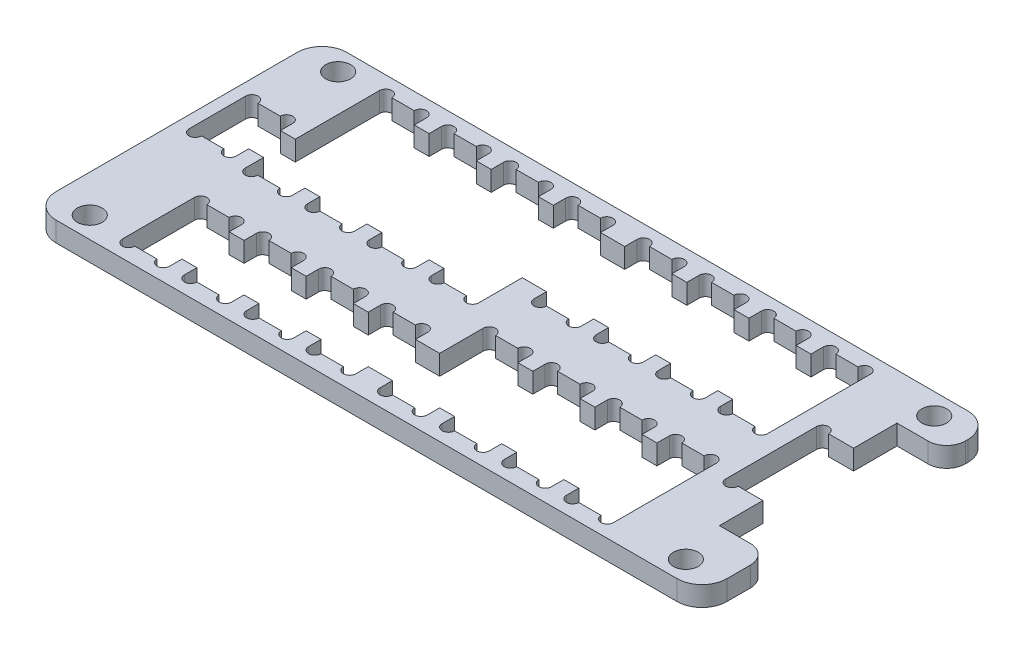
from build123d import *

# Parameters (mm, degrees)
ESQUISSE1_R             = 1
BASE_DEPTH              = 1.6
TROUS_MOLEX_DEPTH       = 2.6
ESQUISSE3_W             = 1.2
ESQUISSE3_H             = 2.55
ESQUISSE3_H_2           = 3.8
ESQUISSE3_H_3           = 8.8
ESQUISSE3_H_4           = 6.3
ESQUISSE3_W_2           = 1.95
ENL_V_MAT_EXTRU_4_DEPTH = 2.6


with BuildPart() as part:
    # Esquisse1 → base (new body)
    with BuildSketch(Plane(origin=(0, 0, 0), x_dir=(1, 0, 0), z_dir=(0, 1, 0))):
        with BuildLine():
            Line((-149, -101.7), (-99, -101.7))
            ThreePointArc((-99, -101.7), (-97.585786438, -101.114213562), (-97, -99.7))
            Line((-97, -99.7), (-97, -80.3))
            ThreePointArc((-97, -80.3), (-97.585786438, -78.885786438), (-99, -78.3))
            Line((-99, -78.3), (-149, -78.3))
            ThreePointArc((-149, -78.3), (-150.414213562, -78.885786438), (-151, -80.3))
            Line((-151, -80.3), (-151, -99.7))
            ThreePointArc((-151, -99.7), (-150.414213562, -101.114213562), (-149, -101.7))
        make_face()
        with Locations((-100, -80)):
            Circle(ESQUISSE1_R, mode=Mode.SUBTRACT)
        with Locations((-100, -100)):
            Circle(ESQUISSE1_R, mode=Mode.SUBTRACT)
        with Locations((-148, -100)):
            Circle(ESQUISSE1_R, mode=Mode.SUBTRACT)
        with Locations((-148, -80)):
            Circle(ESQUISSE1_R, mode=Mode.SUBTRACT)
    extrude(amount=BASE_DEPTH)

    # Esquisse2 → trous molex (cut, through all)
    with BuildSketch(Plane(origin=(0, 0, 0), x_dir=(1, 0, 0), z_dir=(0, 1, 0))):
        with BuildLine():
            Line((-147.227, -89.975), (-149.023, -89.975))
            ThreePointArc((-149.023, -89.975), (-149.524, -90.476), (-150.025, -89.975))
            Line((-150.025, -89.975), (-150.025, -85.425))
            ThreePointArc((-150.025, -85.425), (-149.524, -84.924), (-149.023, -85.425))
            Line((-149.023, -85.425), (-147.227, -85.425))
            ThreePointArc((-147.227, -85.425), (-146.726, -84.924), (-146.225, -85.425))
            Line((-146.225, -85.425), (-146.225, -89.975))
            ThreePointArc((-146.225, -89.975), (-146.726, -90.476), (-147.227, -89.975))
        make_face()
        with BuildLine():
            Line((-144.023, -79.65), (-142.227, -79.65))
            ThreePointArc((-142.227, -79.65), (-141.726, -79.149), (-141.225, -79.65))
            Line((-141.225, -79.65), (-141.225, -90.45))
            ThreePointArc((-141.225, -90.45), (-141.726, -90.951), (-142.227, -90.45))
            Line((-142.227, -90.45), (-144.023, -90.45))
            ThreePointArc((-144.023, -90.45), (-144.524, -90.951), (-145.025, -90.45))
            Line((-145.025, -90.45), (-145.025, -79.65))
            ThreePointArc((-145.025, -79.65), (-144.524, -79.149), (-144.023, -79.65))
        make_face()
        with BuildLine():
            Line((-144.023, -94.55), (-142.227, -94.55))
            ThreePointArc((-142.227, -94.55), (-141.726, -94.049), (-141.225, -94.55))
            Line((-141.225, -94.55), (-141.225, -100.35))
            ThreePointArc((-141.225, -100.35), (-141.726, -100.851), (-142.227, -100.35))
            Line((-142.227, -100.35), (-144.023, -100.35))
            ThreePointArc((-144.023, -100.35), (-144.524, -100.851), (-145.025, -100.35))
            Line((-145.025, -100.35), (-145.025, -94.55))
            ThreePointArc((-145.025, -94.55), (-144.524, -94.049), (-144.023, -94.55))
        make_face()
        with BuildLine():
            Line((-136.225, -79.65), (-136.225, -90.45))
            ThreePointArc((-136.225, -90.45), (-136.726, -90.951), (-137.227, -90.45))
            Line((-137.227, -90.45), (-139.023, -90.45))
            ThreePointArc((-139.023, -90.45), (-139.524, -90.951), (-140.025, -90.45))
            Line((-140.025, -90.45), (-140.025, -79.65))
            ThreePointArc((-140.025, -79.65), (-139.524, -79.149), (-139.023, -79.65))
            Line((-139.023, -79.65), (-137.227, -79.65))
            ThreePointArc((-137.227, -79.65), (-136.726, -79.149), (-136.225, -79.65))
        make_face()
        with BuildLine():
            Line((-136.225, -94.55), (-136.225, -100.35))
            ThreePointArc((-136.225, -100.35), (-136.726, -100.851), (-137.227, -100.35))
            Line((-137.227, -100.35), (-139.023, -100.35))
            ThreePointArc((-139.023, -100.35), (-139.524, -100.851), (-140.025, -100.35))
            Line((-140.025, -100.35), (-140.025, -94.55))
            ThreePointArc((-140.025, -94.55), (-139.524, -94.049), (-139.023, -94.55))
            Line((-139.023, -94.55), (-137.227, -94.55))
            ThreePointArc((-137.227, -94.55), (-136.726, -94.049), (-136.225, -94.55))
        make_face()
        with BuildLine():
            Line((-131.225, -79.65), (-131.225, -90.45))
            ThreePointArc((-131.225, -90.45), (-131.726, -90.951), (-132.227, -90.45))
            Line((-132.227, -90.45), (-134.023, -90.45))
            ThreePointArc((-134.023, -90.45), (-134.524, -90.951), (-135.025, -90.45))
            Line((-135.025, -90.45), (-135.025, -79.65))
            ThreePointArc((-135.025, -79.65), (-134.524, -79.149), (-134.023, -79.65))
            Line((-134.023, -79.65), (-132.227, -79.65))
            ThreePointArc((-132.227, -79.65), (-131.726, -79.149), (-131.225, -79.65))
        make_face()
        with BuildLine():
            Line((-131.225, -94.55), (-131.225, -100.35))
            ThreePointArc((-131.225, -100.35), (-131.726, -100.851), (-132.227, -100.35))
            Line((-132.227, -100.35), (-134.023, -100.35))
            ThreePointArc((-134.023, -100.35), (-134.524, -100.851), (-135.025, -100.35))
            Line((-135.025, -100.35), (-135.025, -94.55))
            ThreePointArc((-135.025, -94.55), (-134.524, -94.049), (-134.023, -94.55))
            Line((-134.023, -94.55), (-132.227, -94.55))
            ThreePointArc((-132.227, -94.55), (-131.726, -94.049), (-131.225, -94.55))
        make_face()
        with BuildLine():
            Line((-126.225, -79.65), (-126.225, -90.45))
            ThreePointArc((-126.225, -90.45), (-126.726, -90.951), (-127.227, -90.45))
            Line((-127.227, -90.45), (-129.023, -90.45))
            ThreePointArc((-129.023, -90.45), (-129.524, -90.951), (-130.025, -90.45))
            Line((-130.025, -90.45), (-130.025, -79.65))
            ThreePointArc((-130.025, -79.65), (-129.524, -79.149), (-129.023, -79.65))
            Line((-129.023, -79.65), (-127.227, -79.65))
            ThreePointArc((-127.227, -79.65), (-126.726, -79.149), (-126.225, -79.65))
        make_face()
        with BuildLine():
            Line((-126.225, -94.55), (-126.225, -100.35))
            ThreePointArc((-126.225, -100.35), (-126.726, -100.851), (-127.227, -100.35))
            Line((-127.227, -100.35), (-129.023, -100.35))
            ThreePointArc((-129.023, -100.35), (-129.524, -100.851), (-130.025, -100.35))
            Line((-130.025, -100.35), (-130.025, -94.55))
            ThreePointArc((-130.025, -94.55), (-129.524, -94.049), (-129.023, -94.55))
            Line((-129.023, -94.55), (-127.227, -94.55))
            ThreePointArc((-127.227, -94.55), (-126.726, -94.049), (-126.225, -94.55))
        make_face()
        with BuildLine():
            Line((-121.477, -79.65), (-123.273, -79.65))
            ThreePointArc((-123.273, -79.65), (-123.774, -79.149), (-124.275, -79.65))
            Line((-124.275, -79.65), (-124.275, -87.95))
            ThreePointArc((-124.275, -87.95), (-123.774, -88.451), (-123.273, -87.95))
            Line((-123.273, -87.95), (-121.477, -87.95))
            ThreePointArc((-121.477, -87.95), (-120.976, -88.451), (-120.475, -87.95))
            Line((-120.475, -87.95), (-120.475, -79.65))
            ThreePointArc((-120.475, -79.65), (-120.976, -79.149), (-121.477, -79.65))
        make_face()
        with BuildLine():
            Line((-121.477, -100.35), (-123.273, -100.35))
            ThreePointArc((-123.273, -100.35), (-123.774, -100.851), (-124.275, -100.35))
            Line((-124.275, -100.35), (-124.275, -92.05))
            ThreePointArc((-124.275, -92.05), (-123.774, -91.549), (-123.273, -92.05))
            Line((-123.273, -92.05), (-121.477, -92.05))
            ThreePointArc((-121.477, -92.05), (-120.976, -91.549), (-120.475, -92.05))
            Line((-120.475, -92.05), (-120.475, -100.35))
            ThreePointArc((-120.475, -100.35), (-120.976, -100.851), (-121.477, -100.35))
        make_face()
        with BuildLine():
            Line((-119.275, -79.65), (-119.275, -87.95))
            ThreePointArc((-119.275, -87.95), (-118.774, -88.451), (-118.273, -87.95))
            Line((-118.273, -87.95), (-116.477, -87.95))
            ThreePointArc((-116.477, -87.95), (-115.976, -88.451), (-115.475, -87.95))
            Line((-115.475, -87.95), (-115.475, -79.65))
            ThreePointArc((-115.475, -79.65), (-115.976, -79.149), (-116.477, -79.65))
            Line((-116.477, -79.65), (-118.273, -79.65))
            ThreePointArc((-118.273, -79.65), (-118.774, -79.149), (-119.275, -79.65))
        make_face()
        with BuildLine():
            Line((-119.275, -100.35), (-119.275, -92.05))
            ThreePointArc((-119.275, -92.05), (-118.774, -91.549), (-118.273, -92.05))
            Line((-118.273, -92.05), (-116.477, -92.05))
            ThreePointArc((-116.477, -92.05), (-115.976, -91.549), (-115.475, -92.05))
            Line((-115.475, -92.05), (-115.475, -100.35))
            ThreePointArc((-115.475, -100.35), (-115.976, -100.851), (-116.477, -100.35))
            Line((-116.477, -100.35), (-118.273, -100.35))
            ThreePointArc((-118.273, -100.35), (-118.774, -100.851), (-119.275, -100.35))
        make_face()
        with BuildLine():
            Line((-114.275, -79.65), (-114.275, -87.95))
            ThreePointArc((-114.275, -87.95), (-113.774, -88.451), (-113.273, -87.95))
            Line((-113.273, -87.95), (-111.477, -87.95))
            ThreePointArc((-111.477, -87.95), (-110.976, -88.451), (-110.475, -87.95))
            Line((-110.475, -87.95), (-110.475, -79.65))
            ThreePointArc((-110.475, -79.65), (-110.976, -79.149), (-111.477, -79.65))
            Line((-111.477, -79.65), (-113.273, -79.65))
            ThreePointArc((-113.273, -79.65), (-113.774, -79.149), (-114.275, -79.65))
        make_face()
        with BuildLine():
            Line((-114.275, -100.35), (-114.275, -92.05))
            ThreePointArc((-114.275, -92.05), (-113.774, -91.549), (-113.273, -92.05))
            Line((-113.273, -92.05), (-111.477, -92.05))
            ThreePointArc((-111.477, -92.05), (-110.976, -91.549), (-110.475, -92.05))
            Line((-110.475, -92.05), (-110.475, -100.35))
            ThreePointArc((-110.475, -100.35), (-110.976, -100.851), (-111.477, -100.35))
            Line((-111.477, -100.35), (-113.273, -100.35))
            ThreePointArc((-113.273, -100.35), (-113.774, -100.851), (-114.275, -100.35))
        make_face()
        with BuildLine():
            Line((-109.275, -79.65), (-109.275, -87.95))
            ThreePointArc((-109.275, -87.95), (-108.774, -88.451), (-108.273, -87.95))
            Line((-108.273, -87.95), (-106.477, -87.95))
            ThreePointArc((-106.477, -87.95), (-105.976, -88.451), (-105.475, -87.95))
            Line((-105.475, -87.95), (-105.475, -79.65))
            ThreePointArc((-105.475, -79.65), (-105.976, -79.149), (-106.477, -79.65))
            Line((-106.477, -79.65), (-108.273, -79.65))
            ThreePointArc((-108.273, -79.65), (-108.774, -79.149), (-109.275, -79.65))
        make_face()
        with BuildLine():
            Line((-109.275, -100.35), (-109.275, -92.05))
            ThreePointArc((-109.275, -92.05), (-108.774, -91.549), (-108.273, -92.05))
            Line((-108.273, -92.05), (-106.477, -92.05))
            ThreePointArc((-106.477, -92.05), (-105.976, -91.549), (-105.475, -92.05))
            Line((-105.475, -92.05), (-105.475, -100.35))
            ThreePointArc((-105.475, -100.35), (-105.976, -100.851), (-106.477, -100.35))
            Line((-106.477, -100.35), (-108.273, -100.35))
            ThreePointArc((-108.273, -100.35), (-108.774, -100.851), (-109.275, -100.35))
        make_face()
        with BuildLine():
            Line((-100.998, -85.5), (-102.998, -85.5))
            ThreePointArc((-102.998, -85.5), (-103.499, -84.999), (-104, -85.5))
            Line((-104, -85.5), (-104, -92.8))
            ThreePointArc((-104, -92.8), (-103.499, -93.301), (-102.998, -92.8))
            Line((-102.998, -92.8), (-100.998, -92.8))
            Line((-100.998, -92.8), (-100.998, -96.3))
            Line((-100.998, -96.3), (-98.5, -96.3))
            ThreePointArc((-98.5, -96.3), (-97.439339828, -96.739339828), (-97, -97.8))
            Line((-97, -97.8), (-97, -80.5))
            ThreePointArc((-97, -80.5), (-97.439339828, -81.560660172), (-98.5, -82))
            Line((-98.5, -82), (-100.998, -82))
            Line((-100.998, -82), (-100.998, -85.5))
        make_face()
    extrude(amount=TROUS_MOLEX_DEPTH, mode=Mode.SUBTRACT)

    # Esquisse3 → Enlèv. mat.-Extru.4 (cut, through all)
    with BuildSketch(Plane(origin=(0, 0, 0), x_dir=(1, 0, 0), z_dir=(0, 1, 0))):
        with Locations((-145.625, -87.7)):
            Rectangle(ESQUISSE3_W, ESQUISSE3_H)
        with Locations((-135.625, -97.45)):
            Rectangle(ESQUISSE3_W, ESQUISSE3_H_2)
        with Locations((-140.625, -97.45)):
            Rectangle(ESQUISSE3_W, ESQUISSE3_H_2)
        with Locations((-130.625, -97.45)):
            Rectangle(ESQUISSE3_W, ESQUISSE3_H_2)
        with Locations((-135.625, -85.05)):
            Rectangle(ESQUISSE3_W, ESQUISSE3_H_3)
        with Locations((-140.625, -85.05)):
            Rectangle(ESQUISSE3_W, ESQUISSE3_H_3)
        with Locations((-130.625, -85.05)):
            Rectangle(ESQUISSE3_W, ESQUISSE3_H_3)
        with Locations((-119.875, -83.8)):
            Rectangle(ESQUISSE3_W, ESQUISSE3_H_4)
        with Locations((-119.875, -96.2)):
            Rectangle(ESQUISSE3_W, ESQUISSE3_H_4)
        with Locations((-114.875, -83.8)):
            Rectangle(ESQUISSE3_W, ESQUISSE3_H_4)
        with Locations((-114.875, -96.2)):
            Rectangle(ESQUISSE3_W, ESQUISSE3_H_4)
        with Locations((-109.875, -83.8)):
            Rectangle(ESQUISSE3_W, ESQUISSE3_H_4)
        with Locations((-109.875, -96.2)):
            Rectangle(ESQUISSE3_W, ESQUISSE3_H_4)
        with Locations((-125.25, -97.45)):
            Rectangle(ESQUISSE3_W_2, ESQUISSE3_H_2)
        with Locations((-125.25, -83.8)):
            Rectangle(ESQUISSE3_W_2, ESQUISSE3_H_4)
    extrude(amount=ENL_V_MAT_EXTRU_4_DEPTH, mode=Mode.SUBTRACT)


solid = part.part
